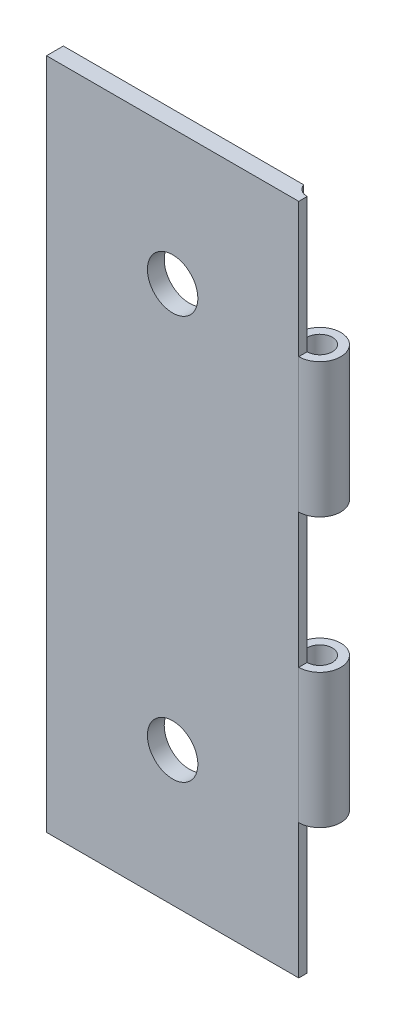
from build123d import *

# Parameters (mm, degrees)
SKETCH1_W           = 15
SKETCH1_H           = 40
SKETCH1_R           = 1.5
BOSS_EXTRUDE2_DEPTH = 1
BOSS_EXTRUDE5_START = -8
BOSS_EXTRUDE5_DEPTH = 8
LPATTERN2_COUNT     = 2
LPATTERN2_PITCH     = 16
SKETCH6_R           = 0.75
CUT_EXTRUDE3_DEPTH  = 40


with BuildPart() as part:
    # Sketch1 → Boss-Extrude2 (new body)
    with BuildSketch(Plane.XY):
        Rectangle(SKETCH1_W, SKETCH1_H)
        with Locations((0, 12)):
            Circle(SKETCH1_R, mode=Mode.SUBTRACT)
        with Locations((0, -12)):
            Circle(SKETCH1_R, mode=Mode.SUBTRACT)
    extrude(amount=BOSS_EXTRUDE2_DEPTH)

    # Sketch5 → Boss-Extrude5 (add)
    with BuildSketch(Plane(origin=(0, 20, 0), x_dir=(1, 0, 0), z_dir=(0, 1, 0)).offset(BOSS_EXTRUDE5_START)):
        with BuildLine():
            Line((7.5, -0.5), (7.5, -1))
            ThreePointArc((7.5, -1), (8.383883476, -0.633883476), (8.75, 0.25))
            ThreePointArc((8.75, 0.25), (7.374363797, 1.493670191), (6.275255129, 0))
            Line((6.275255129, 0), (6.792893219, 0))
            ThreePointArc((6.792893219, 0), (7.373173516, 0.98919892), (8.25, 0.25))
            ThreePointArc((8.25, 0.25), (8.030330086, -0.280330086), (7.5, -0.5))
        make_face()
        with BuildLine():
            ThreePointArc((6.275255129, 0), (6.709430585, -0.718245837), (7.5, -1))
            Line((7.5, -1), (7.5, -0.5))
            ThreePointArc((7.5, -0.5), (7.066987298, -0.362372436), (6.792893219, 0))
            Line((6.792893219, 0), (6.275255129, 0))
        make_face()
    boss_extrude5 = extrude(amount=-BOSS_EXTRUDE5_DEPTH)

    # LPattern2: Boss-Extrude5 ×2
    with Locations(*[(0, -i * LPATTERN2_PITCH, 0) for i in range(1, LPATTERN2_COUNT)]):
        add(boss_extrude5)

    # Sketch6 → Cut-Extrude3 (cut)
    with BuildSketch(Plane(origin=(0, 20, 0), x_dir=(1, 0, 0), z_dir=(0, 1, 0))):
        with Locations((7.5, 0.25)):
            Circle(SKETCH6_R)
    extrude(amount=-CUT_EXTRUDE3_DEPTH, mode=Mode.SUBTRACT)


solid = part.part
